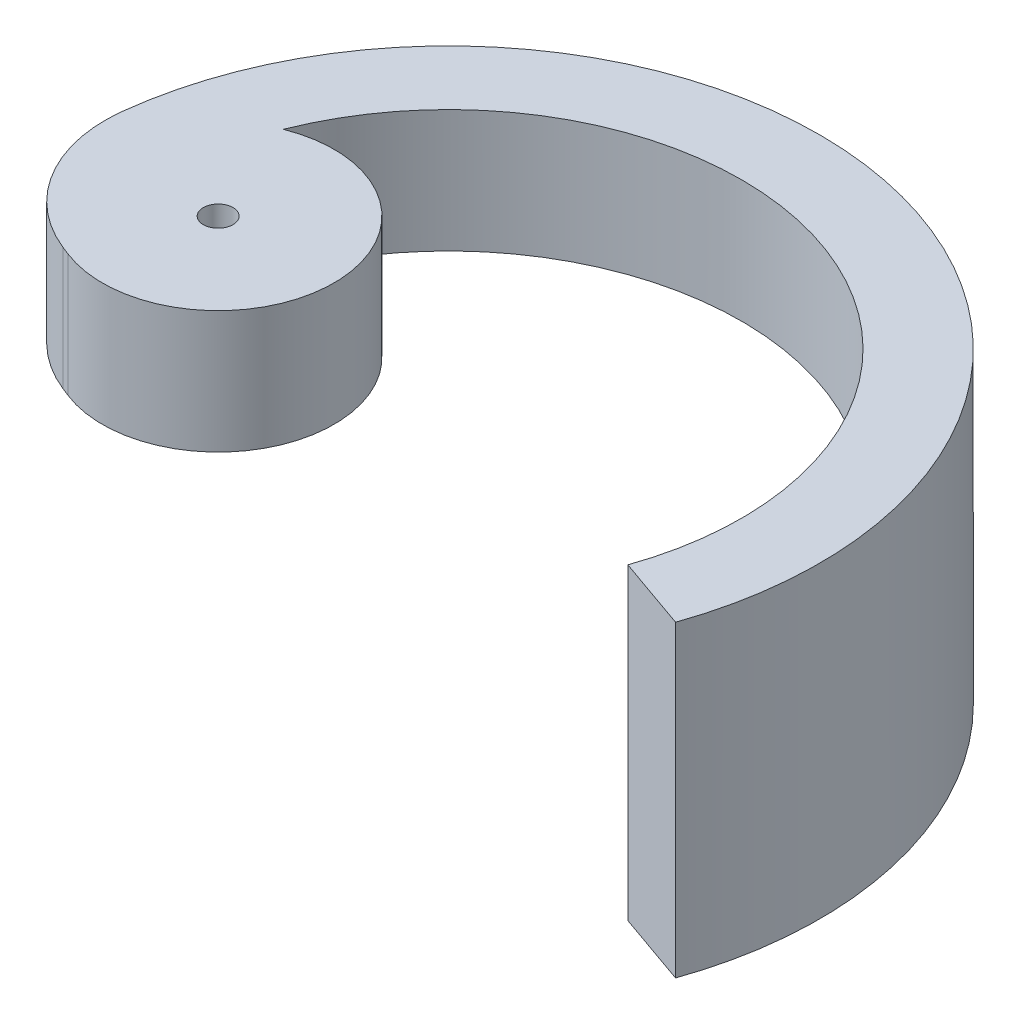
from build123d import *

# Parameters (mm, degrees)
SKETCH4_R           = 1.016
BOSS_EXTRUDE3_DEPTH = 8.382
BOSS_EXTRUDE4_DEPTH = 12.7
FILLET4_R           = 9.652


with BuildPart() as part:
    # Sketch4 → Boss-Extrude3 (new body)
    with BuildSketch(Plane(origin=(0, 0, 0), x_dir=(1, 0, 0), z_dir=(0, 1, 0))):
        with BuildLine():
            Line((-18.663003184, -7.371341), (-24.923761703, -4.89551862))
            ThreePointArc((-24.923761703, -4.89551862), (1.824176411, 25.334410994), (23.965300472, -8.415721794))
            Line((23.965300472, -8.415721794), (18.932587373, -6.648420217))
            ThreePointArc((18.932587373, -6.648420217), (7.011176439, 18.801270195), (-18.663003184, 7.371341))
            ThreePointArc((-18.663003184, 7.371341), (-7.821215551, 0), (-18.663003184, -7.371341))
        make_face()
        with Locations((-15.748, 0)):
            Circle(SKETCH4_R, mode=Mode.SUBTRACT)
    extrude(amount=BOSS_EXTRUDE3_DEPTH)

    # Sketch5 → Boss-Extrude4 (add)
    with BuildSketch(Plane.XZ):
        with BuildLine():
            Line((18.932587373, 6.648420217), (23.965300472, 8.415721794))
            ThreePointArc((23.965300472, 8.415721794), (24.582982591, -6.390380813), (16.83300832, -19.021299401))
            Line((16.83300832, -19.021299401), (13.298076573, -15.026826527))
            ThreePointArc((13.298076573, -15.026826527), (19.420556247, -5.048400842), (18.932587373, 6.648420217))
        make_face()
    extrude(amount=BOSS_EXTRUDE4_DEPTH)

    # Fillet4
    fillet4_edges = [part.edges().sort_by_distance(p)[0] for p in [
        (-24.923761703, 4.191, 4.89551862),
    ]]
    fillet(fillet4_edges, radius=FILLET4_R)


solid = part.part
